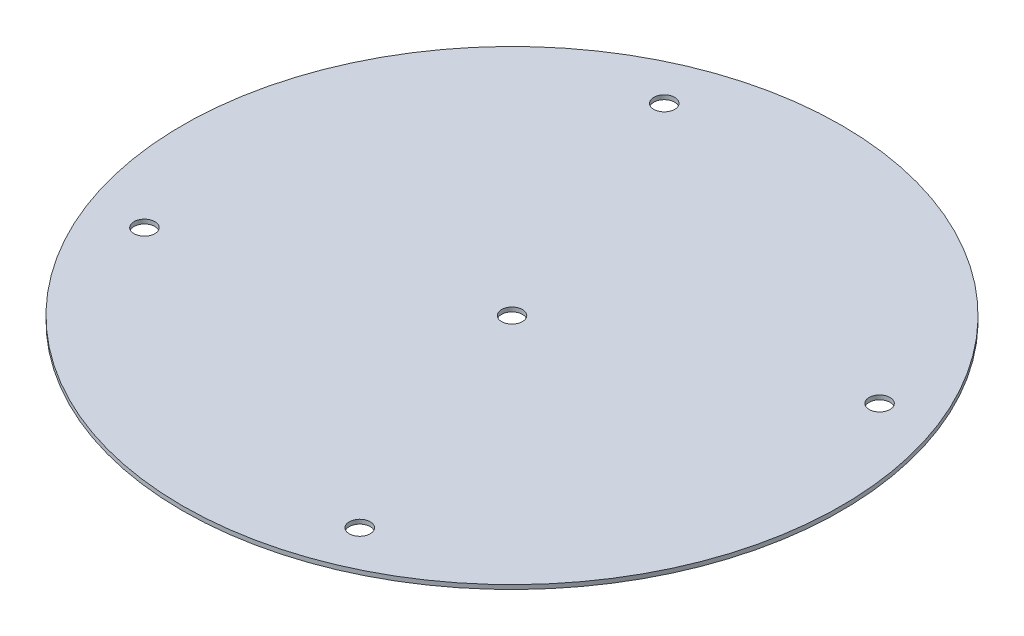
from build123d import *

# Parameters (mm, degrees)
SKETCH2_W                    = 77.55
SKETCH2_H                    = 1
F_10_0_1935_DIAMETER_HOLE1_D = 4.9149
CIRPATTERN3_COUNT            = 4
F_10_0_1935_DIAMETER_HOLE2_D = 4.9149


with BuildPart() as part:
    # Sketch2 → Revolve1 (revolve)
    with BuildSketch(Plane(origin=(0, 0, 0), x_dir=(0, 0, -1), z_dir=(1, 0, 0))):
        with Locations((-38.775, 0.5)):
            Rectangle(SKETCH2_W, SKETCH2_H)
    revolve(axis=Axis((0, -0.05, 0), (0, 1, 0)))

    # #10 (0.1935) Diameter Hole1 (through all)
    with Locations(Plane(origin=(0, 1, 0), x_dir=(1, 0, 0), z_dir=(0, 1, 0))):
        with Locations((-25.333643223, 61.160825052)):
            f_10_0_1935_diameter_hole1 = Hole(F_10_0_1935_DIAMETER_HOLE1_D / 2)

    # CirPattern3: #10 (0.1935) Diameter Hole1 ×4 about axis
    cirpattern3_axis = Axis((0, 0, 0), (0, 1, 0))
    for i in range(1, CIRPATTERN3_COUNT):
        add(f_10_0_1935_diameter_hole1.rotate(cirpattern3_axis, i * 360 / CIRPATTERN3_COUNT), mode=Mode.SUBTRACT)

    # #10 (0.1935) Diameter Hole2 (through all)
    with Locations(Plane(origin=(0, 1, 0), x_dir=(1, 0, 0), z_dir=(0, 1, 0))):
        with Locations((0, 0)):
            Hole(F_10_0_1935_DIAMETER_HOLE2_D / 2)


solid = part.part
